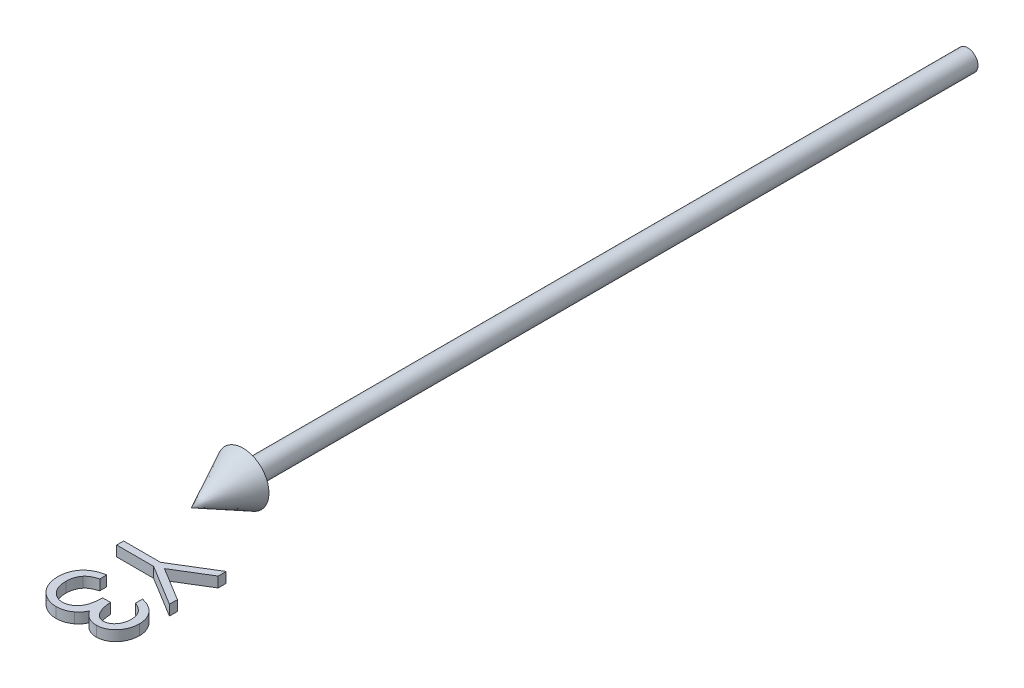
from build123d import *

# Parameters (mm, degrees)
BOSS_EXTRUDE1_DEPTH        = 1
BOSS_EXTRUDE1_DEPTH_BACK   = 1
BOSS_EXTRUDE1_2_DEPTH      = 1
BOSS_EXTRUDE1_2_DEPTH_BACK = 1


with BuildPart() as part:
    # Sketch2 → Revolve1 (revolve)
    with BuildSketch(Plane(origin=(0, 0, 0), x_dir=(1, 0, 0), z_dir=(0, 1, 0))):
        Polygon((0, -150), (5, -140), (2, -140), (2, 0), (0, 0), align=None)
    revolve(axis=Axis((0, 0, -41.949952025), (0, 0, 1)))


with BuildPart() as body_2:
    # Sketch3 → Boss-Extrude1 (new, two sides: drawn at the far end of the back side and taken through both)
    with BuildSketch(Plane(origin=(0, 0, 0), x_dir=(1, 0, 0), z_dir=(0, 1, 0)).offset(-BOSS_EXTRUDE1_DEPTH_BACK)):
        Polygon((15, -158.269230769), (15, -159.810697115), (8.5546875, -163.753004808), (15, -167.689302885), (15, -169.230769231), (7.130408654, -164.423076923), (0, -164.423076923), (0, -163.076923077), (7.130408654, -163.076923077), align=None)
    extrude(amount=BOSS_EXTRUDE1_DEPTH + BOSS_EXTRUDE1_DEPTH_BACK)


with BuildPart() as body_3:
    # Sketch3 → Boss-Extrude1 2 (new, two sides: drawn at the far end of the back side and taken through both)
    with BuildSketch(Plane(origin=(0, 0, 0), x_dir=(1, 0, 0), z_dir=(0, 1, 0)).offset(-BOSS_EXTRUDE1_2_DEPTH_BACK)):
        with BuildLine():
            Line((11.538461538, -172.307692308), (11.538461538, -170.961538462))
            add(Edge.make_bspline(
                [(11.538461538, -170.961538462), (11.689457898, -170.998007964), (11.984643431, -171.06930286), (12.406388835, -171.218006746), (12.805489641, -171.380003554), (13.174472814, -171.574528288), (13.520753826, -171.786708663), (13.836478645, -172.029806041), (14.129677068, -172.292604852), (14.389876658, -172.583283206), (14.625495497, -172.888120328), (14.8263886, -173.211411555), (14.999206398, -173.546652528), (15.141578821, -173.896165955), (15.248831065, -174.260992405), (15.326645946, -174.637833648), (15.377179293, -175.02767722), (15.382111134, -175.292309751), (15.384615385, -175.426682692)],
                knots=[0, 0, 0, 0, 1.162005537, 2.271625781, 3.343758855, 4.383309926, 5.390229558, 6.379919256, 7.361854164, 8.333198761, 9.295911338, 10.242430842, 11.177959212, 12.116337295, 13.062827104, 14.020064771, 14.994644689, 16, 16, 16, 16], degree=3))
            add(Edge.make_bspline(
                [(15.384615385, -175.426682692), (15.378704398, -175.622465873), (15.36701136, -176.009761634), (15.260235204, -176.578746121), (15.091270351, -177.127432488), (14.85781152, -177.649814979), (14.569865892, -178.135036833), (14.227159877, -178.566763348), (13.836305728, -178.93914268), (13.404594738, -179.251547155), (12.943213983, -179.496154294), (12.468356167, -179.676524466), (11.981147718, -179.78633167), (11.65218795, -179.800562628), (11.487379808, -179.807692308)],
                knots=[0, 0, 0, 0, 1.083050992, 2.142477498, 3.193116406, 4.255571735, 5.30263384, 6.308962982, 7.297363603, 8.282367274, 9.249857812, 10.179914175, 11.08814088, 12, 12, 12, 12], degree=3))
            add(Edge.make_bspline(
                [(11.487379808, -179.807692308), (11.328779259, -179.802705489), (11.018422597, -179.792947058), (10.565330466, -179.71008832), (10.138295037, -179.570647194), (9.735518627, -179.377491068), (9.359555028, -179.127455853), (9.009558353, -178.824572866), (8.683976247, -178.466704316), (8.49746422, -178.195508867), (8.401442308, -178.055889423)],
                knots=[0, 0, 0, 0, 1.024540389, 2.004866551, 2.965041327, 3.920577974, 4.882998113, 5.874504559, 6.905732034, 8, 8, 8, 8], degree=3))
            add(Edge.make_bspline(
                [(8.401442308, -178.055889423), (8.324393001, -178.215454086), (8.17173604, -178.531597832), (7.872354222, -178.962528673), (7.526684162, -179.353719568), (7.256929935, -179.571878363), (7.121394231, -179.681490385)],
                knots=[0, 0, 0, 0, 1.015518401, 2.012035669, 3.001164323, 4, 4, 4, 4], degree=3))
            add(Edge.make_bspline(
                [(7.121394231, -179.681490385), (7.022585827, -179.753696946), (6.826587074, -179.896927638), (6.511277108, -180.073222124), (6.193516116, -180.234984199), (5.860810145, -180.354036403), (5.523846298, -180.456773737), (5.175408835, -180.524371482), (4.818808204, -180.567766531), (4.577450896, -180.573860082), (4.456129808, -180.576923077)],
                knots=[0, 0, 0, 0, 1.02516404, 2.033540309, 3.025129118, 4.011046665, 4.991655828, 5.976607087, 6.982917762, 8, 8, 8, 8], degree=3))
            add(Edge.make_bspline(
                [(4.456129808, -180.576923077), (4.246096498, -180.56921537), (3.827018298, -180.553836228), (3.207715637, -180.416929931), (2.603383897, -180.203463888), (2.022977307, -179.905624451), (1.481063404, -179.537118827), (0.998397563, -179.096277372), (0.580716501, -178.59381687), (0.232859438, -178.033025827), (-0.045411202, -177.425720035), (-0.238500659, -176.776095844), (-0.364273007, -176.093599566), (-0.377759067, -175.625567745), (-0.384615385, -175.387620192)],
                knots=[0, 0, 0, 0, 0.95570045, 1.906903359, 2.87519758, 3.868912786, 4.869932978, 5.851730567, 6.836639976, 7.83677598, 8.849487602, 9.869908895, 10.917060885, 12, 12, 12, 12], degree=3))
            add(Edge.make_bspline(
                [(-0.384615385, -175.387620192), (-0.380894471, -175.227251763), (-0.373572953, -174.911700169), (-0.323521805, -174.447799462), (-0.232107497, -174.004992179), (-0.109093331, -173.582679617), (0.046871278, -173.180486604), (0.24109427, -172.799640439), (0.469572136, -172.437798038), (0.735001798, -172.098373961), (1.031921825, -171.781408671), (1.365603296, -171.495325567), (1.729877885, -171.235355026), (2.128976697, -171.008458003), (2.557742085, -170.804299635), (3.021664221, -170.636381249), (3.516595744, -170.488585955), (3.861500345, -170.419871108), (4.038461538, -170.384615385)],
                knots=[0, 0, 0, 0, 1.048658725, 2.063410685, 3.046034179, 4.001477787, 4.936774919, 5.862367409, 6.792675028, 7.730719943, 8.675894397, 9.627829632, 10.600096036, 11.597688215, 12.626045268, 13.701542398, 14.82072376, 16, 16, 16, 16], degree=3))
            Line((4.038461538, -170.384615385), (4.038461538, -171.730769231))
            add(Edge.make_bspline(
                [(4.038461538, -171.730769231), (3.922965767, -171.76584048), (3.69831646, -171.834057105), (3.375000865, -171.950175526), (3.078609208, -172.08246812), (2.806967257, -172.224387657), (2.557399817, -172.37343814), (2.336506093, -172.540216391), (2.134583798, -172.71236987), (2.020821175, -172.842138527), (1.965144231, -172.905649038)],
                knots=[0, 0, 0, 0, 1.198163088, 2.33053128, 3.407730985, 4.417276592, 5.372219308, 6.28897303, 7.162600585, 8, 8, 8, 8], degree=3))
            add(Edge.make_bspline(
                [(1.965144231, -172.905649038), (1.900394228, -172.989634366), (1.771094092, -173.157345779), (1.606087113, -173.430638198), (1.46311129, -173.718059138), (1.353895451, -174.025836313), (1.261419762, -174.347328187), (1.200903251, -174.687731181), (1.159382517, -175.044042111), (1.155718525, -175.287332526), (1.153846154, -175.411658654)],
                knots=[0, 0, 0, 0, 0.946170439, 1.889420265, 2.845303464, 3.807233317, 4.801018734, 5.828864929, 6.890507805, 8, 8, 8, 8], degree=3))
            add(Edge.make_bspline(
                [(1.153846154, -175.411658654), (1.156481455, -175.552032708), (1.161634559, -175.826522053), (1.209161849, -176.227016332), (1.2780779, -176.608143103), (1.385876004, -176.966012969), (1.515197637, -177.305495661), (1.68450339, -177.619012944), (1.875706866, -177.915781839), (2.098113283, -178.187108389), (2.338510547, -178.43172254), (2.593550619, -178.643096194), (2.855325599, -178.826169953), (3.129942168, -178.973330702), (3.414706557, -179.089741763), (3.710684643, -179.168941716), (4.015384104, -179.224023302), (4.222508678, -179.228508287), (4.326923077, -179.230769231)],
                knots=[0, 0, 0, 0, 1.216990249, 2.379719373, 3.493992396, 4.571561497, 5.616923107, 6.638958652, 7.655775068, 8.674704564, 9.676001865, 10.625896028, 11.54399481, 12.441854662, 13.322657739, 14.20572845, 15.095482574, 16, 16, 16, 16], degree=3))
            add(Edge.make_bspline(
                [(4.326923077, -179.230769231), (4.466686116, -179.224210912), (4.745516752, -179.211126908), (5.155732562, -179.111231252), (5.550984985, -178.946928637), (5.924473647, -178.716876933), (6.270794327, -178.436968597), (6.578588517, -178.109913124), (6.835117225, -177.734908249), (7.011701967, -177.387539637), (7.129388272, -177.07910962), (7.211907706, -176.81568588), (7.277872279, -176.520514097), (7.341679886, -176.197137744), (7.395172135, -175.844192982), (7.439973989, -175.46136183), (7.475766198, -175.048490273), (7.491758771, -174.762671565), (7.5, -174.615384615)],
                knots=[0, 0, 0, 0, 1.070481957, 2.135637345, 3.216366529, 4.339485895, 5.485746587, 6.620975969, 7.768829582, 8.956804399, 9.598399438, 10.297751078, 11.070570279, 11.915248466, 12.824061284, 13.805856426, 14.869322739, 16, 16, 16, 16], degree=3))
            Line((7.5, -174.615384615), (9.038461538, -174.615384615))
            add(Edge.make_bspline(
                [(9.038461538, -174.615384615), (9.041624428, -174.800955911), (9.047819752, -175.164444492), (9.122232223, -175.695492287), (9.226325481, -176.203907783), (9.382087198, -176.678085824), (9.569045715, -177.108873005), (9.779855096, -177.484667358), (10.018692666, -177.796562705), (10.282423912, -178.045338288), (10.568581806, -178.227930733), (10.863711079, -178.364984447), (11.174678411, -178.445330888), (11.386778343, -178.456116914), (11.493389423, -178.461538462)],
                knots=[0, 0, 0, 0, 1.321708579, 2.588902423, 3.815526512, 5.016621128, 6.138757764, 7.158873101, 8.079948563, 8.928590313, 9.728601868, 10.489025425, 11.240515403, 12, 12, 12, 12], degree=3))
            add(Edge.make_bspline(
                [(11.493389423, -178.461538462), (11.571722805, -178.459762621), (11.727563353, -178.456229671), (11.955239455, -178.411666876), (12.17596811, -178.344718025), (12.388747781, -178.252618656), (12.592343397, -178.129569953), (12.78700473, -177.981870519), (12.975994101, -177.809449065), (13.150270028, -177.607799361), (13.314656854, -177.389492051), (13.456763151, -177.152472999), (13.577212353, -176.90196995), (13.676729071, -176.63775255), (13.751541535, -176.35876235), (13.805270227, -176.066365438), (13.838859158, -175.759988922), (13.843695367, -175.550967315), (13.846153846, -175.444711538)],
                knots=[0, 0, 0, 0, 0.884317272, 1.759307272, 2.611736065, 3.488921043, 4.37244062, 5.294096728, 6.247679003, 7.258495569, 8.302441962, 9.333537773, 10.376747089, 11.440883505, 12.520330301, 13.637364711, 14.798958396, 16, 16, 16, 16], degree=3))
            add(Edge.make_bspline(
                [(13.846153846, -175.444711538), (13.840202433, -175.273913032), (13.828577938, -174.940303823), (13.726403869, -174.459461387), (13.56451959, -174.012914697), (13.369044803, -173.672736196), (13.176749979, -173.421110148), (13.011318743, -173.237853128), (12.823753604, -173.061174589), (12.608909862, -172.898007556), (12.374175124, -172.738574717), (12.118256559, -172.584398415), (11.837505532, -172.440430797), (11.640073318, -172.352795351), (11.538461538, -172.307692308)],
                knots=[0, 0, 0, 0, 1.4727372, 2.876598283, 4.222346151, 5.558423782, 6.24313385, 6.953189256, 7.68715613, 8.463578749, 9.278833271, 10.135787152, 11.040551781, 12, 12, 12, 12], degree=3))
        make_face()
    extrude(amount=BOSS_EXTRUDE1_2_DEPTH + BOSS_EXTRUDE1_2_DEPTH_BACK)


solid = Compound([part.part, body_2.part, body_3.part])
